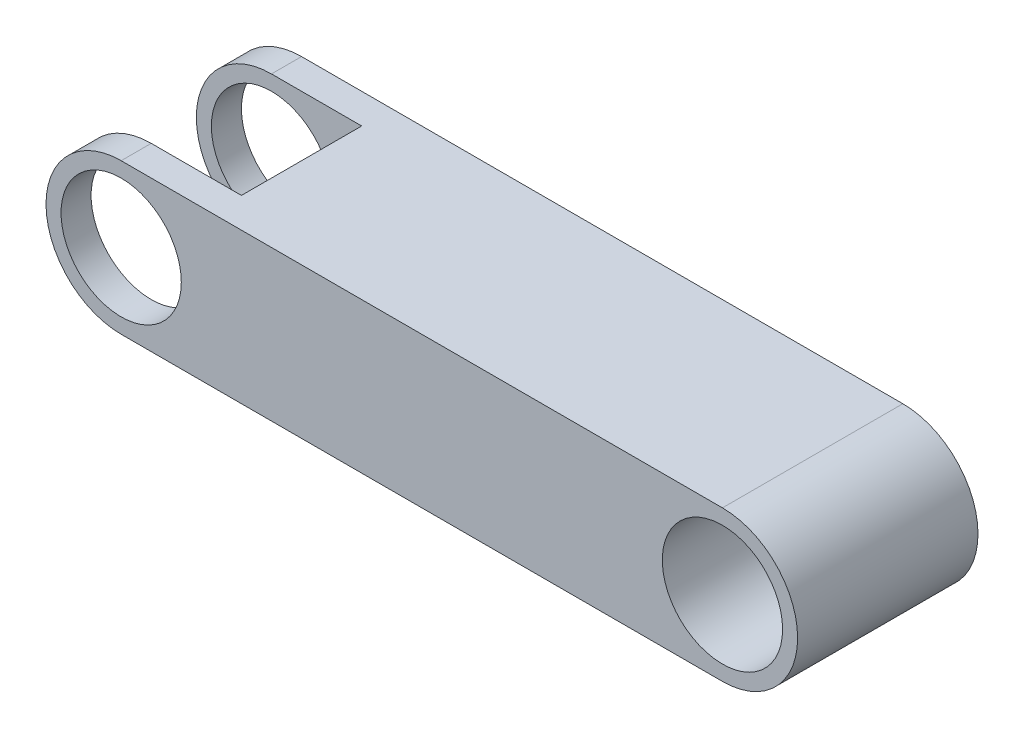
from build123d import *

# Parameters (mm, degrees)
SKETCH3_R           = 10
BOSS_EXTRUDE2_DEPTH = 15
SKETCH4_W           = 20
SKETCH4_H           = 25
CUT_EXTRUDE2_DEPTH  = 15


with BuildPart() as part:
    # Sketch3 → Boss-Extrude2 (new body, symmetric)
    with BuildSketch(Plane.XY):
        with BuildLine():
            Line((0, 12.5), (100, 12.5))
            ThreePointArc((100, 12.5), (112.5, 0), (100, -12.5))
            Line((100, -12.5), (0, -12.5))
            ThreePointArc((0, -12.5), (-12.5, 0), (0, 12.5))
        make_face()
        Circle(SKETCH3_R, mode=Mode.SUBTRACT)
        with Locations((100, 0)):
            Circle(SKETCH3_R, mode=Mode.SUBTRACT)
    extrude(amount=BOSS_EXTRUDE2_DEPTH, both=True)

    # Sketch4 → Cut-Extrude2 (cut, symmetric)
    with BuildSketch(Plane(origin=(0, 0, 0), x_dir=(0, 0, -1), z_dir=(1, 0, 0))):
        Rectangle(SKETCH4_W, SKETCH4_H)
    extrude(amount=CUT_EXTRUDE2_DEPTH, both=True, mode=Mode.SUBTRACT)


solid = part.part
